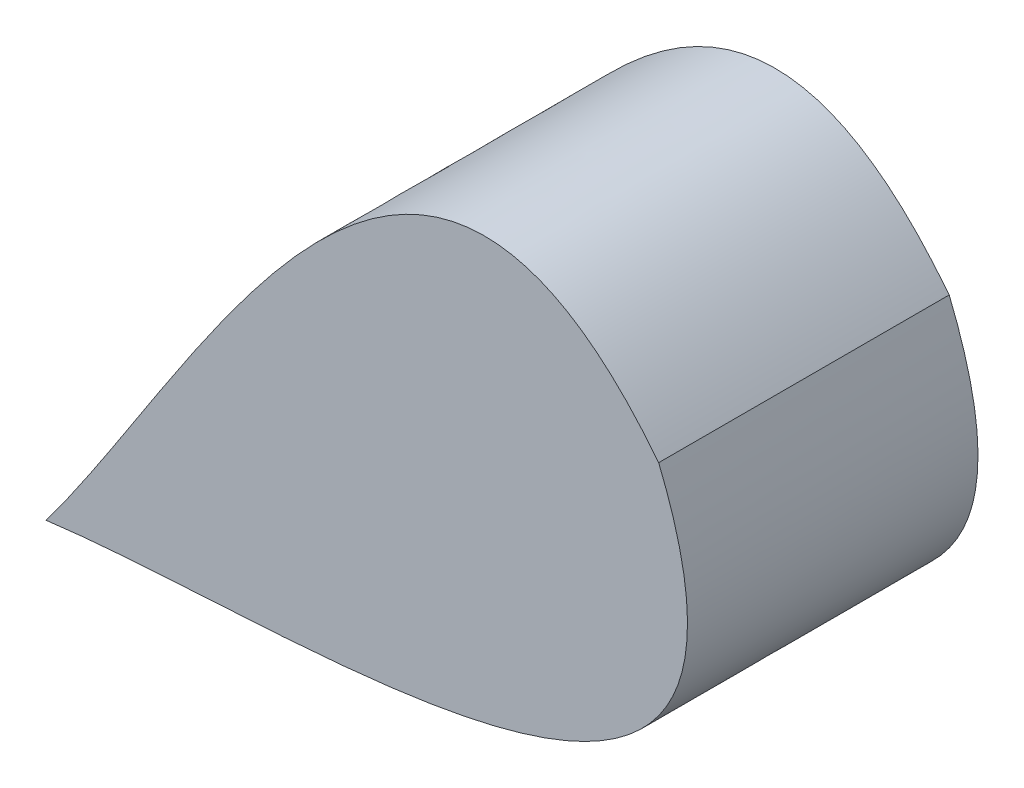
from build123d import *

# Parameters (mm, degrees)
BOSS_EXTRUDE1_DEPTH = 10


with BuildPart() as part:
    # Sketch1 → Boss-Extrude1 (new body)
    with BuildSketch(Plane.XY):
        with BuildLine():
            add(Edge.make_bspline(
                [(948.090064485, 759.213189708), (953.531720886, 766.401913097), (960.540224931, 782.530385898), (969.179875653, 771.473957673)],
                knots=[0, 0, 0, 0, 1, 1, 1, 1], degree=3))
            add(Edge.make_bspline(
                [(948.090064485, 759.213189708), (957.029634779, 760.385133096), (974.513214795, 758.495372877), (969.179875653, 771.473957673)],
                knots=[0, 0, 0, 0, 1, 1, 1, 1], degree=3))
        make_face()
    extrude(amount=BOSS_EXTRUDE1_DEPTH)


solid = part.part
